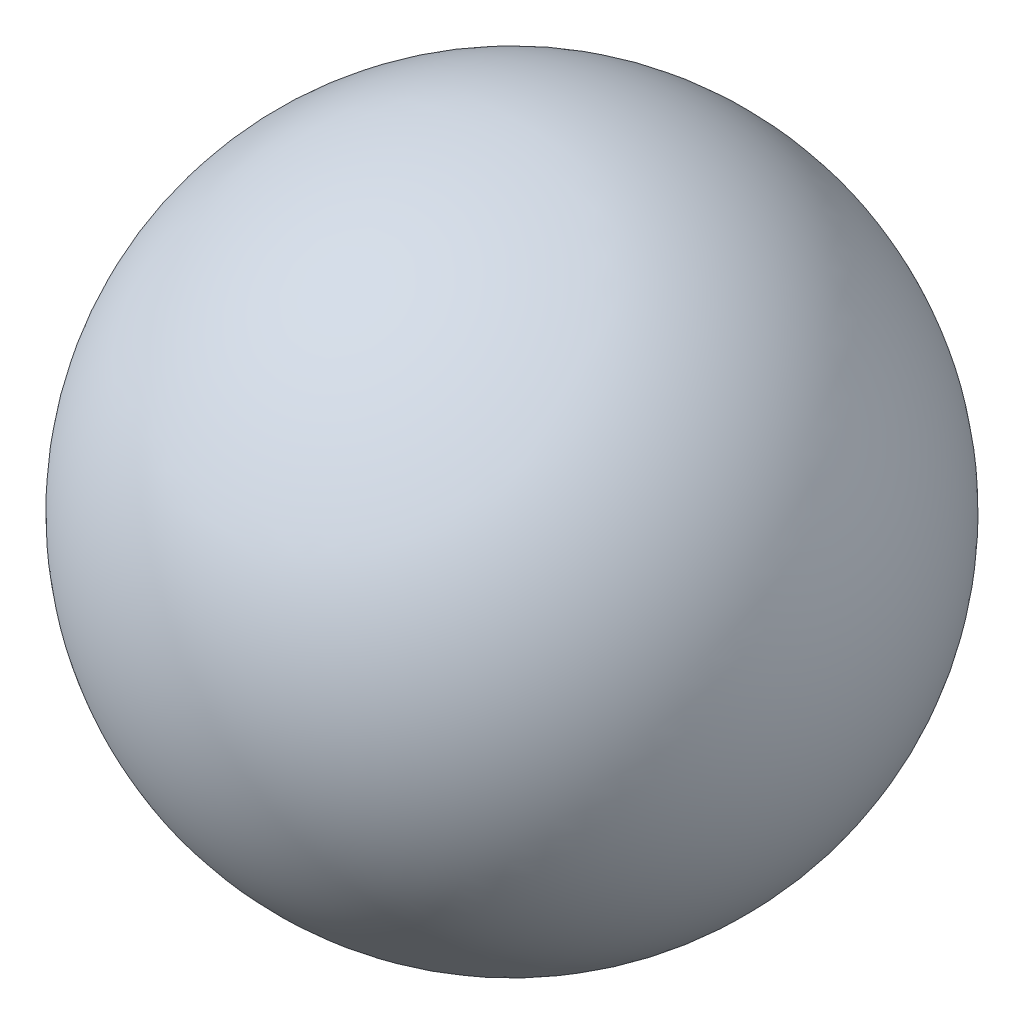
from build123d import *


with BuildPart() as part:
    # Sketch1 → Revolve1 (revolve)
    with BuildSketch(Plane(origin=(0, 0, 0), x_dir=(1, 0, 0), z_dir=(0, 1, 0))):
        with BuildLine():
            Line((0, 0.25), (0, -0.25))
            ThreePointArc((0, -0.25), (0.25, 0), (0, 0.25))
        make_face()
    revolve(axis=Axis((0, 0, -0.371290082), (0, 0, 1)))


solid = part.part
